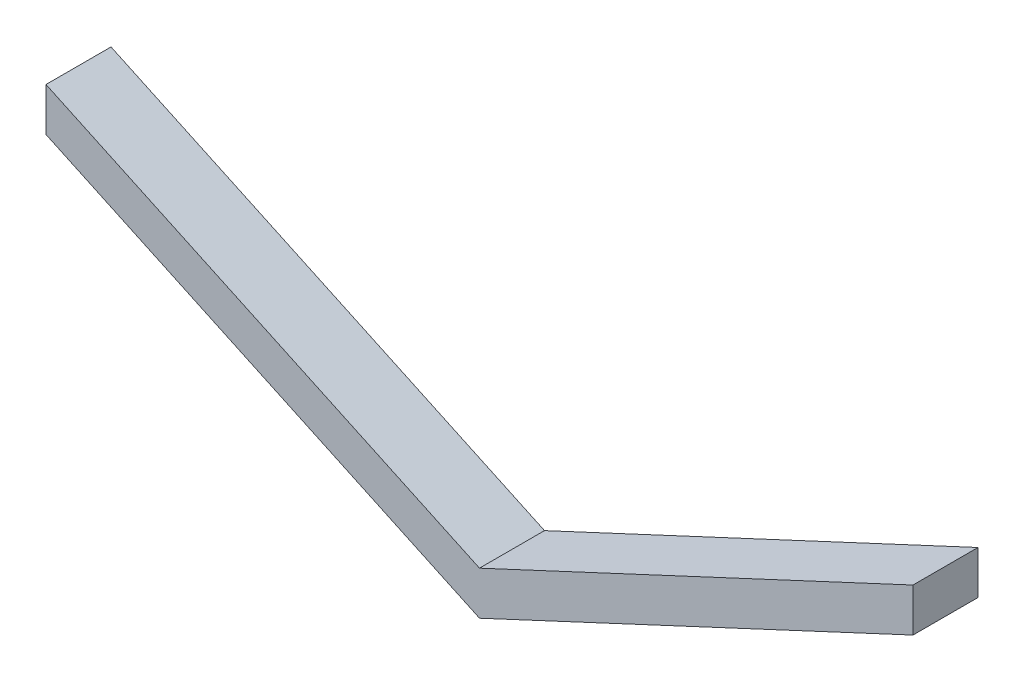
from build123d import *

# Parameters (mm, degrees)
BOSS_EXTRU_1_DEPTH = 30


with BuildPart() as part:
    # Esquisse1 → Boss.-Extru.1 (new body)
    with BuildSketch(Plane.XY):
        Polygon((-200, 113.261531631), (0, 20), (200, 113.261531631), (200, 93.261531631), (0, 0), (-200, 93.261531631), align=None)
    extrude(amount=BOSS_EXTRU_1_DEPTH)


solid = part.part
